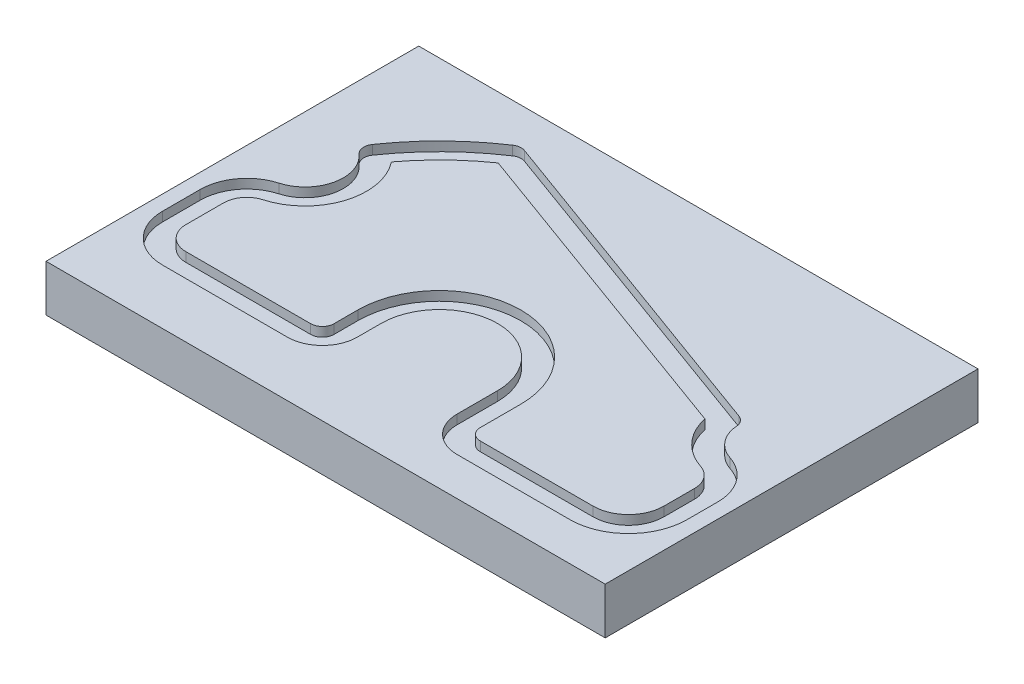
from build123d import *

# Parameters (mm, degrees)
BOSS_EXTRUDE1_DEPTH = 2.54
BOSS_EXTRUDE2_DEPTH = 10.16
BOSS_EXTRUDE4_DEPTH = 2.54
FILLET1_R           = 3.175
FILLET2_R           = 3.175
FILLET3_R           = 3.175


with BuildPart() as part:
    # Sketch1 → Boss-Extrude1 (new body)
    with BuildSketch(Plane(origin=(0, 0, 0), x_dir=(1, 0, 0), z_dir=(0, 1, 0))):
        with BuildLine():
            Line((-59.436, -9.652), (-25.4, -9.652))
            ThreePointArc((-25.4, -9.652), (-23.15493597, -8.72206403), (-22.225, -6.477))
            Line((-22.225, -6.477), (-22.225, 0))
            ThreePointArc((-22.225, 0), (0, 22.225), (22.225, 0))
            Line((22.225, 0), (22.225, -11.049))
            ThreePointArc((22.225, -11.049), (23.15493597, -13.29406403), (25.4, -14.224))
            Line((25.4, -14.224), (56.134, -14.224))
            ThreePointArc((56.134, -14.224), (62.958994652, -11.396994652), (65.786, -4.572))
            Line((65.786, -4.572), (65.786, 3.786270628))
            ThreePointArc((65.786, 3.786270628), (64.573284533, 7.518670343), (61.398344054, 9.825451517))
            ThreePointArc((61.398344054, 9.825451517), (54.523861552, 14.288596243), (50.799961303, 21.590016478))
            Line((50.799961303, 21.590016478), (-37.803944764, 53.839200926))
            ThreePointArc((-37.803944764, 53.839200926), (-45.754351941, 47.268774836), (-52.580093852, 39.536458193))
            ThreePointArc((-52.580093852, 39.536458193), (-49.843866059, 24.02540152), (-61.180505495, 13.091032404))
            ThreePointArc((-61.180505495, 13.091032404), (-64.505522161, 10.809293437), (-65.786, 6.98536286))
            Line((-65.786, 6.98536286), (-65.786, -3.302))
            ThreePointArc((-65.786, -3.302), (-63.926128061, -7.792128061), (-59.436, -9.652))
        make_face()
    extrude(amount=BOSS_EXTRUDE1_DEPTH)

    # Sketch2 → Boss-Extrude2 (add)
    with BuildSketch(Plane.XZ):
        Polygon((-76.199999672, 30.988), (-76.199999672, -70.600237501), (76.199999874, -70.612), (76.200000328, 30.988), align=None)
    extrude(amount=BOSS_EXTRUDE2_DEPTH)

    # Sketch9 → Boss-Extrude4 (add)
    with BuildSketch(Plane(origin=(0, 2.54, 0), x_dir=(1, 0, 0), z_dir=(0, 1, 0))):
        Polygon((76.200000328, -30.988), (76.199999874, 70.612), (-76.199999672, 70.600237501), (-76.199999672, -30.988), align=None)
        with BuildLine():
            Line((15.875, 0), (15.875, -11.049))
            ThreePointArc((15.875, -11.049), (18.664807909, -17.784192091), (25.4, -20.574))
            Line((25.4, -20.574), (56.134, -20.574))
            ThreePointArc((56.134, -20.574), (67.449122713, -15.887122713), (72.136, -4.572))
            Line((72.136, -4.572), (72.136, 3.786270628))
            ThreePointArc((72.136, 3.786270628), (69.710569066, 11.251070057), (63.360688108, 15.864632407))
            ThreePointArc((63.360688108, 15.864632407), (58.26569903, 19.828002779), (56.883535343, 26.133305464))
            Line((56.883535343, 26.133305464), (-38.653299329, 60.905869561))
            ThreePointArc((-38.653299329, 60.905869561), (-51.084372013, 50.931222566), (-61.021650194, 38.47025739))
            ThreePointArc((-61.021650194, 38.47025739), (-55.422413128, 28.186543533), (-62.925010989, 19.196701948))
            ThreePointArc((-62.925010989, 19.196701948), (-69.575044323, 14.633224013), (-72.136, 6.98536286))
            Line((-72.136, 6.98536286), (-72.136, -3.302))
            ThreePointArc((-72.136, -3.302), (-68.416256121, -12.282256121), (-59.436, -16.002))
            Line((-59.436, -16.002), (-25.4, -16.002))
            ThreePointArc((-25.4, -16.002), (-18.664807909, -13.212192091), (-15.875, -6.477))
            Line((-15.875, -6.477), (-15.875, 0))
            ThreePointArc((-15.875, 0), (0, 15.875), (15.875, 0))
        make_face(mode=Mode.SUBTRACT)
    extrude(amount=-BOSS_EXTRUDE4_DEPTH)

    # Fillet1
    fillet1_edges = [part.edges().sort_by_distance(p)[0] for p in [
        (-38.653299329, 1.27, -60.905869561),
    ]]
    fillet(fillet1_edges, radius=FILLET1_R)

    # Fillet2
    fillet2_edges = [part.edges().sort_by_distance(p)[0] for p in [
        (56.883535343, 1.27, -26.133305464),
    ]]
    fillet(fillet2_edges, radius=FILLET2_R)

    # Fillet3
    fillet3_edges = [part.edges().sort_by_distance(p)[0] for p in [
        (-61.021650194, 1.27, -38.47025739),
    ]]
    fillet(fillet3_edges, radius=FILLET3_R)


solid = part.part
